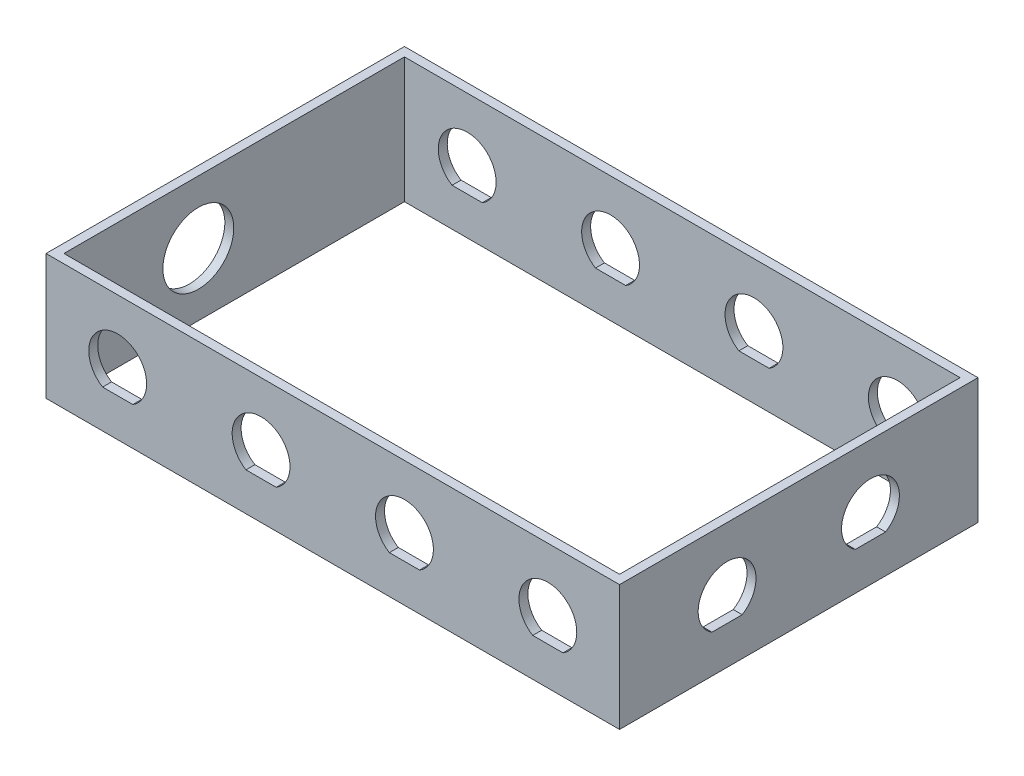
from build123d import *

# Parameters (mm, degrees)
SKETCH1_W           = 203.2
SKETCH1_H           = 127
BOSS_EXTRUDE1_DEPTH = 44.45
SKETCH2_W           = 196.85
SKETCH2_H           = 120.65
CUT_EXTRUDE1_DEPTH  = 45.45
SKETCH4_W           = 203.2
SKETCH4_H           = 127
SKETCH4_W_2         = 196.85
SKETCH4_H_2         = 120.65
BOSS_EXTRUDE2_DEPTH = 6.35
CUT_EXTRUDE5_DEPTH  = 128
CUT_EXTRUDE6_REACH  = 205.2
CUT_EXTRUDE7_REACH  = 205.2
SKETCH13_R          = 12.55395


with BuildPart() as part:
    # Sketch1 → Boss-Extrude1 (new body)
    with BuildSketch(Plane(origin=(0, 0, 0), x_dir=(1, 0, 0), z_dir=(0, 1, 0))):
        Rectangle(SKETCH1_W, SKETCH1_H)
    extrude(amount=BOSS_EXTRUDE1_DEPTH)

    # Sketch2 → Cut-Extrude1 (cut, through all)
    with BuildSketch(Plane(origin=(0, 44.45, 0), x_dir=(1, 0, 0), z_dir=(0, 1, 0))):
        Rectangle(SKETCH2_W, SKETCH2_H)
    extrude(amount=-CUT_EXTRUDE1_DEPTH, mode=Mode.SUBTRACT)

    # Sketch4 → Boss-Extrude2 (add)
    with BuildSketch(Plane(origin=(0, 44.45, 0), x_dir=(1, 0, 0), z_dir=(0, 1, 0))):
        Rectangle(SKETCH4_W, SKETCH4_H)
        Rectangle(SKETCH4_W_2, SKETCH4_H_2, mode=Mode.SUBTRACT)
    extrude(amount=-BOSS_EXTRUDE2_DEPTH)

    # Sketch10 → Cut-Extrude5 (cut, through all)
    with BuildSketch(Plane.XY.offset(63.5)):
        with BuildLine():
            ThreePointArc((-65.9511, 22.225), (-81.206975571, 31.167602912), (-81.556705839, 13.4874))
            Line((-81.556705839, 13.4874), (-70.843294161, 13.4874))
            ThreePointArc((-70.843294161, 13.4874), (-67.257397088, 17.218024429), (-65.9511, 22.225))
        make_face()
        with BuildLine():
            ThreePointArc((-15.1511, 22.225), (-30.406975571, 31.167602912), (-30.756705839, 13.4874))
            Line((-30.756705839, 13.4874), (-20.043294161, 13.4874))
            ThreePointArc((-20.043294161, 13.4874), (-16.457397088, 17.218024429), (-15.1511, 22.225))
        make_face()
        with BuildLine():
            ThreePointArc((35.6489, 22.225), (20.393024429, 31.167602912), (20.043294161, 13.4874))
            Line((20.043294161, 13.4874), (30.756705839, 13.4874))
            ThreePointArc((30.756705839, 13.4874), (34.342602912, 17.218024429), (35.6489, 22.225))
        make_face()
        with BuildLine():
            Line((70.843294161, 13.4874), (81.556705839, 13.4874))
            ThreePointArc((81.556705839, 13.4874), (85.142602912, 17.218024429), (86.4489, 22.225))
            ThreePointArc((86.4489, 22.225), (71.193024429, 31.167602912), (70.843294161, 13.4874))
        make_face()
    extrude(amount=-CUT_EXTRUDE5_DEPTH, mode=Mode.SUBTRACT)

    # Sketch12 → Cut-Extrude6 (cut, up to next)
    with BuildSketch(Plane(origin=(101.6, 0, 0), x_dir=(0, 0, -1), z_dir=(1, 0, 0)), mode=Mode.PRIVATE) as cut_extrude6_sk1:
        with BuildLine():
            ThreePointArc((-20.043294161, 13.4874), (-25.4, 32.4739), (-30.756705839, 13.4874))
            Line((-30.756705839, 13.4874), (-20.043294161, 13.4874))
        make_face()
    cut_extrude6_tool1 = extrude(cut_extrude6_sk1.sketch, amount=-CUT_EXTRUDE6_REACH, mode=Mode.PRIVATE) & part.part
    add(cut_extrude6_tool1.solids().sort_by_distance((101.6, 22.546198, 25.4))[0], mode=Mode.SUBTRACT)
    # Sketch12 → Cut-Extrude6 (cut, up to next)
    with BuildSketch(Plane(origin=(101.6, 0, 0), x_dir=(0, 0, -1), z_dir=(1, 0, 0)), mode=Mode.PRIVATE) as cut_extrude6_sk2:
        with BuildLine():
            ThreePointArc((30.756705839, 13.4874), (25.4, 32.4739), (20.043294161, 13.4874))
            Line((20.043294161, 13.4874), (30.756705839, 13.4874))
        make_face()
    cut_extrude6_tool2 = extrude(cut_extrude6_sk2.sketch, amount=-CUT_EXTRUDE6_REACH, mode=Mode.PRIVATE) & part.part
    add(cut_extrude6_tool2.solids().sort_by_distance((101.6, 22.546198, -25.4))[0], mode=Mode.SUBTRACT)

    # Sketch13 → Cut-Extrude7 (cut, up to next)
    with BuildSketch(Plane.ZY.offset(101.6), mode=Mode.PRIVATE) as cut_extrude7_sk1:
        with Locations((12.7, 22.225)):
            Circle(SKETCH13_R)
    cut_extrude7_tool1 = extrude(cut_extrude7_sk1.sketch, amount=-CUT_EXTRUDE7_REACH, mode=Mode.PRIVATE) & part.part
    add(cut_extrude7_tool1.solids().sort_by_distance((-101.6, 22.225, 12.7))[0], mode=Mode.SUBTRACT)


solid = part.part
